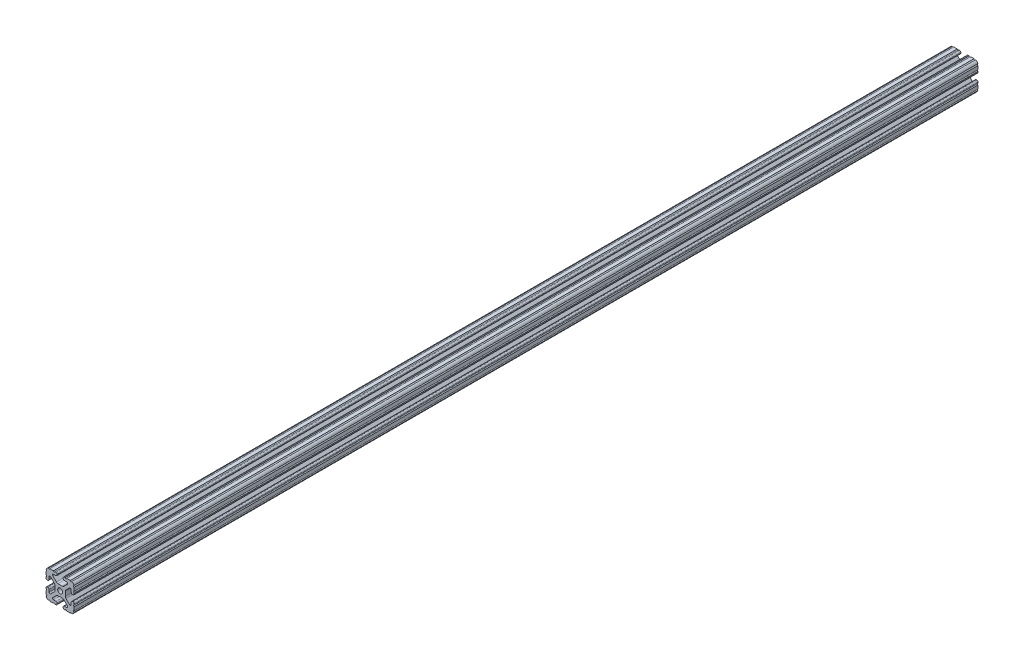
from build123d import *

# Parameters (mm, degrees)
BOSS_EXTRUDE1_DEPTH     = 609.6
SKETCH5_R               = 1.016
CUT_EXTRUDE1_DEPTH      = 610.6
CUT_EXTRUDE1_DEPTH_BACK = 610.6


with BuildPart() as part:
    # Sketch4 → Boss-Extrude1 (new body, symmetric)
    with BuildSketch(Plane.XY):
        with BuildLine():
            Line((5.7912, -19.05), (14.3002, -19.05))
            ThreePointArc((14.3002, -19.05), (17.658815789, -17.658815789), (19.05, -14.3002))
            Line((19.05, -14.3002), (19.05, -5.7912))
            ThreePointArc((19.05, -5.7912), (18.544114832, -4.569885168), (17.3228, -4.064))
            Line((17.3228, -4.064), (16.7132, -4.064))
            ThreePointArc((16.7132, -4.064), (15.491885168, -4.569885168), (14.986, -5.7912))
            Line((14.986, -5.7912), (14.986, -8.996305235))
            ThreePointArc((14.986, -8.996305235), (14.189232738, -10.188751711), (12.782646215, -9.908964256))
            Line((12.782646215, -9.908964256), (7.888897763, -5.015215804))
            ThreePointArc((7.888897763, -5.015215804), (7.219915375, -4.014012907), (6.985, -2.833013566))
            Line((6.985, -2.833013566), (6.985, 0))
            Line((6.985, 0), (3.3274, 0))
            ThreePointArc((3.3274, 0), (2.352827104, -2.352827104), (0, -3.3274))
            Line((0, -3.3274), (0, -6.985))
            Line((0, -6.985), (2.833013566, -6.985))
            ThreePointArc((2.833013566, -6.985), (4.014012907, -7.219915375), (5.015215804, -7.888897763))
            Line((5.015215804, -7.888897763), (9.908964256, -12.782646215))
            ThreePointArc((9.908964256, -12.782646215), (10.188751711, -14.189232738), (8.996305235, -14.986))
            Line((8.996305235, -14.986), (5.7912, -14.986))
            ThreePointArc((5.7912, -14.986), (4.569885168, -15.491885168), (4.064, -16.7132))
            Line((4.064, -16.7132), (4.064, -17.3228))
            ThreePointArc((4.064, -17.3228), (4.569885168, -18.544114832), (5.7912, -19.05))
        make_face()
    extrude(amount=BOSS_EXTRUDE1_DEPTH, both=True)

    # Sketch5 → Cut-Extrude1 (cut, two sides)
    with BuildSketch(Plane.XY) as cut_extrude1_sk:
        with Locations((14.739477062, -19.05)):
            Circle(SKETCH5_R)
        with Locations((7.980305235, -19.05)):
            Circle(SKETCH5_R)
        with Locations((19.05, -14.739477062)):
            Circle(SKETCH5_R)
        with Locations((19.05, -7.980305235)):
            Circle(SKETCH5_R)
    extrude(amount=CUT_EXTRUDE1_DEPTH, mode=Mode.SUBTRACT)
    extrude(cut_extrude1_sk.sketch, amount=-CUT_EXTRUDE1_DEPTH_BACK, mode=Mode.SUBTRACT)

    # Mirror1: part across plane


with BuildPart() as part_1:
    add(part.part)
    add(part.part.mirror(Plane(origin=(0, 0, 0), x_dir=(0, 0, 1), z_dir=(1, 0, 0))))

    # Mirror2: part across plane


with BuildPart() as part_2:
    add(part_1.part)
    add(part_1.part.mirror(Plane.ZX))


solid = part_2.part
